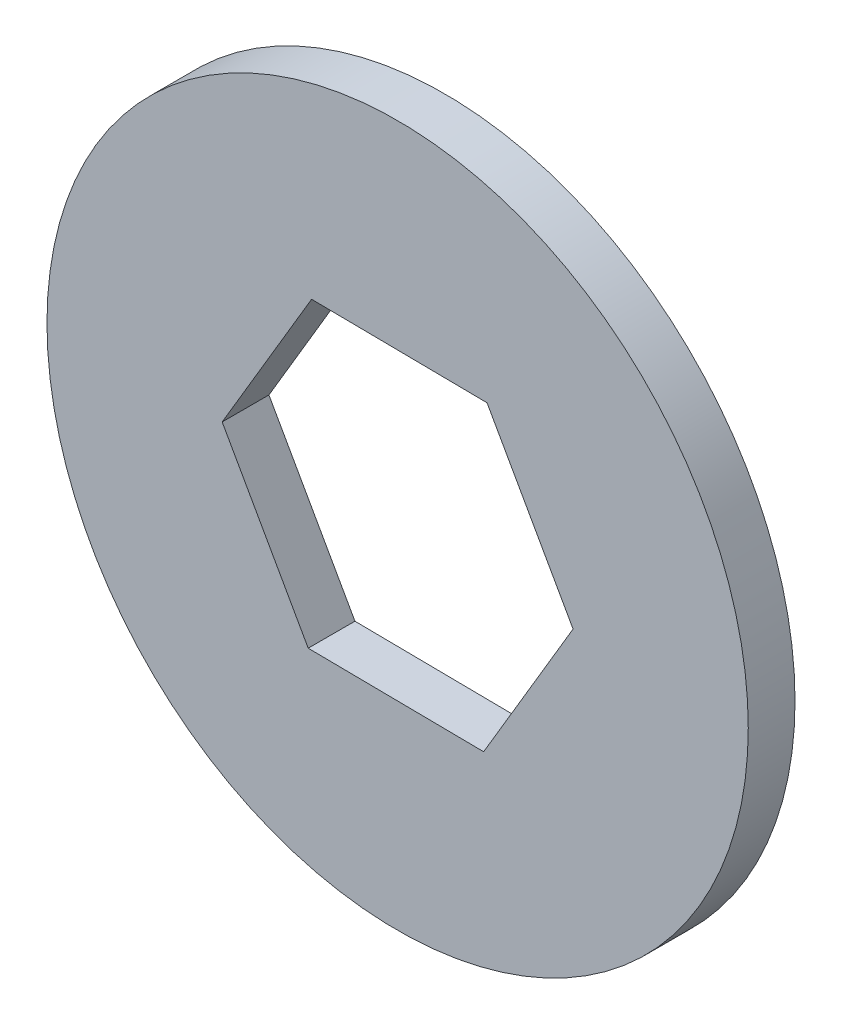
from build123d import *

# Parameters (mm, degrees)
CROQUIS1_R              = 15
SALIENTE_EXTRUIR1_DEPTH = 2


with BuildPart() as part:
    # Croquis1 → Saliente-Extruir1 (new body)
    with BuildSketch(Plane.XY):
        Circle(CROQUIS1_R)
        Polygon((3.679984632, -6.541486562), (7.505085857, -0.083783104), (3.825101225, 6.457703458), (-3.679984632, 6.541486562), (-7.505085857, 0.083783104), (-3.825101225, -6.457703458), align=None, mode=Mode.SUBTRACT)
    extrude(amount=SALIENTE_EXTRUIR1_DEPTH)


solid = part.part
